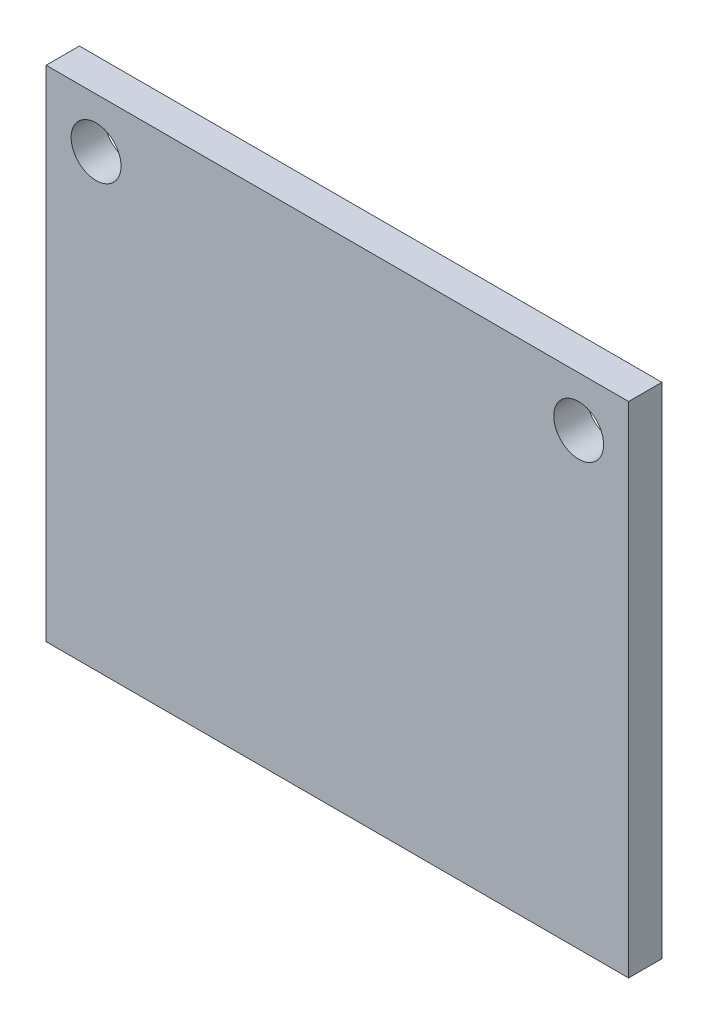
from build123d import *

# Parameters (mm, degrees)
SKETCH1_W           = 35
SKETCH1_H           = 30
BOSS_EXTRUDE1_DEPTH = 2
SKETCH2_R           = 1.5
CUT_EXTRUDE1_DEPTH  = 2


with BuildPart() as part:
    # Sketch1 → Boss-Extrude1 (new body)
    with BuildSketch(Plane.XY):
        with Locations((4.300341297, -6.936860068)):
            Rectangle(SKETCH1_W, SKETCH1_H)
    extrude(amount=BOSS_EXTRUDE1_DEPTH)

    # Sketch2 → Cut-Extrude1 (cut)
    with BuildSketch(Plane.XY.offset(2)):
        with Locations((-10.199658703, 5.063139932)):
            Circle(SKETCH2_R)
        with Locations((18.800341297, 5.063139932)):
            Circle(SKETCH2_R)
    extrude(amount=-CUT_EXTRUDE1_DEPTH, mode=Mode.SUBTRACT)


solid = part.part
